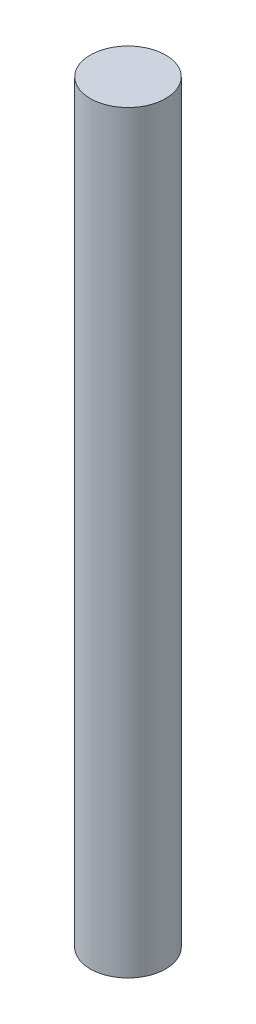
from build123d import *

# Parameters (mm, degrees)
SKETCH1_W = 26.25
SKETCH1_H = 525


with BuildPart() as part:
    # Sketch1 → Revolve1 (revolve)
    with BuildSketch(Plane(origin=(0, 0, 0), x_dir=(-1, 0, 0), z_dir=(0, 0, -1))):
        with Locations((-13.125, 262.5)):
            Rectangle(SKETCH1_W, SKETCH1_H)
    revolve(axis=Axis((0, 0, 0), (0, 1, 0)))


solid = part.part
